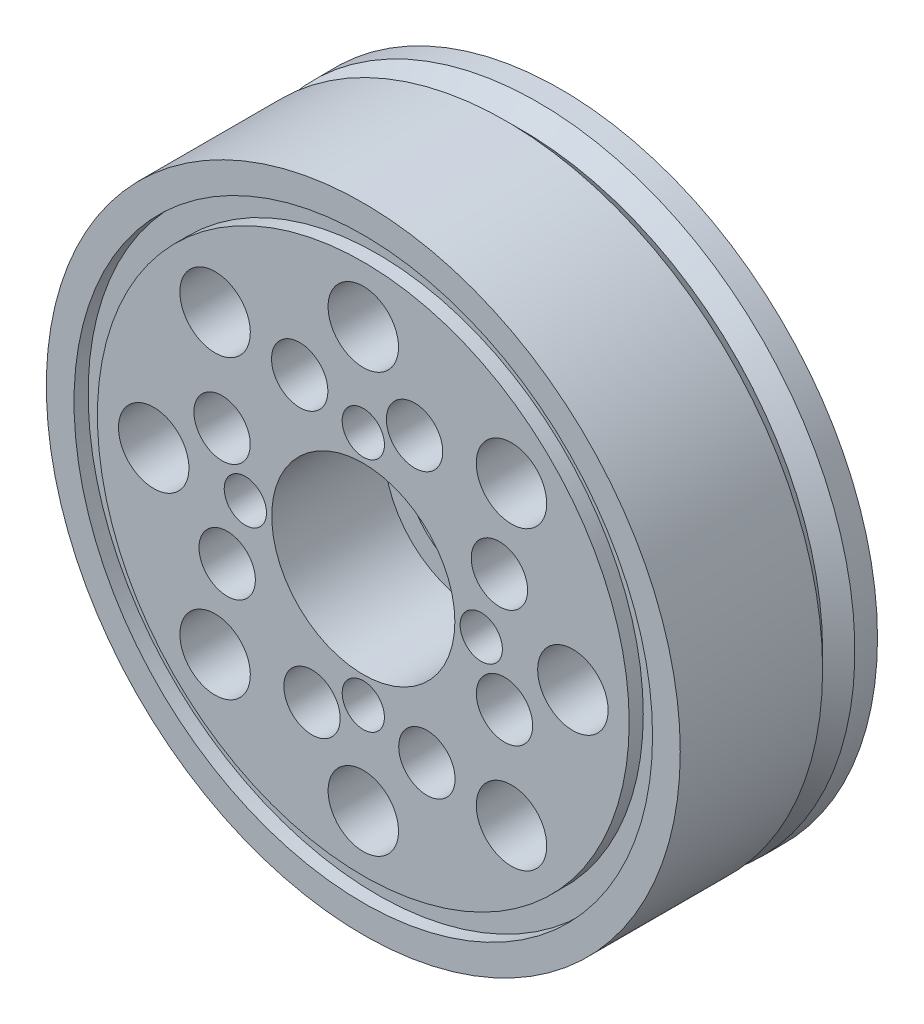
from build123d import *

# Parameters (mm, degrees)
SKETCH_1_R               = 22.5
EXTRUDE_1_DEPTH          = 14
SKETCH_4_R               = 20.533551365
SKETCH_4_R_2             = 18.873819988
CUT_EXTRUDE_2_DEPTH      = 1
SKETCH_5_R               = 6.5
CUT_EXTRUDE_3_DEPTH      = 8
SKETCH_6_R               = 5
CUT_EXTRUDE_4_DEPTH      = 8
SKETCH_7_R               = 1.5
CUT_EXTRUDE_5_DEPTH      = 5
PATTERN_CIRCULAR_1_COUNT = 4
SKETCH_8_R               = 2.5
CUT_EXTRUDE_6_DEPTH      = 5
PATTERN_CIRCULAR_2_COUNT = 8
SKETCH_9_R               = 2
CUT_EXTRUDE_10_DEPTH     = 5
PATTERN_CIRCULAR_3_COUNT = 8
SCALE_1_SCALE            = 1.2444444


with BuildPart() as part:
    # 草图1 → 凸台-拉伸1 (new body)
    with BuildSketch(Plane.XY):
        Circle(SKETCH_1_R)
    extrude(amount=EXTRUDE_1_DEPTH)

    # 草图4 → 切除-拉伸2 (cut)
    with BuildSketch(Plane.XY.offset(14)):
        Circle(SKETCH_4_R)
        Circle(SKETCH_4_R_2, mode=Mode.SUBTRACT)
    extrude(amount=-CUT_EXTRUDE_2_DEPTH, mode=Mode.SUBTRACT)

    # 草图5 → 切除-拉伸3 (cut)
    with BuildSketch(Plane.XY.offset(14)):
        Circle(SKETCH_5_R)
    extrude(amount=-CUT_EXTRUDE_3_DEPTH, mode=Mode.SUBTRACT)

    # 草图6 → 切除-拉伸4 (cut)
    with BuildSketch(Plane.XY.offset(6)):
        Circle(SKETCH_6_R)
    extrude(amount=-CUT_EXTRUDE_4_DEPTH, mode=Mode.SUBTRACT)

    # 草图7 → 切除-拉伸5 (cut)
    with BuildSketch(Plane.XY.offset(14)):
        with Locations((0, 8.372803667)):
            Circle(SKETCH_7_R)
    cut_extrude_5 = extrude(amount=-CUT_EXTRUDE_5_DEPTH, mode=Mode.SUBTRACT)

    # 阵列(圆周)1: 切除-拉伸5 ×4 about axis
    pattern_circular_1_axis = Axis((0, 0, 0), (0, 0, 1))
    for i in range(1, PATTERN_CIRCULAR_1_COUNT):
        add(cut_extrude_5.rotate(pattern_circular_1_axis, i * 360 / PATTERN_CIRCULAR_1_COUNT), mode=Mode.SUBTRACT)

    # 草图8 → 切除-拉伸6 (cut)
    with BuildSketch(Plane.XY.offset(14)):
        with Locations((0, 14.876496216)):
            Circle(SKETCH_8_R)
    cut_extrude_6 = extrude(amount=-CUT_EXTRUDE_6_DEPTH, mode=Mode.SUBTRACT)

    # 阵列(圆周)2: 切除-拉伸6 ×8 about axis
    pattern_circular_2_axis = Axis((0, 0, 0), (0, 0, 1))
    for i in range(1, PATTERN_CIRCULAR_2_COUNT):
        add(cut_extrude_6.rotate(pattern_circular_2_axis, i * 360 / PATTERN_CIRCULAR_2_COUNT), mode=Mode.SUBTRACT)

    # 草图9 → 切除-拉伸10 (cut)
    with BuildSketch(Plane.XY.offset(14)):
        with Locations((-4.513696744, 9.661753254)):
            Circle(SKETCH_9_R)
    cut_extrude_10 = extrude(amount=-CUT_EXTRUDE_10_DEPTH, mode=Mode.SUBTRACT)

    # 阵列(圆周)3: 切除-拉伸10 ×8 about axis
    pattern_circular_3_axis = Axis((0, 0, 0), (0, 0, 1))
    for i in range(1, PATTERN_CIRCULAR_3_COUNT):
        add(cut_extrude_10.rotate(pattern_circular_3_axis, i * 360 / PATTERN_CIRCULAR_3_COUNT), mode=Mode.SUBTRACT)


with BuildPart() as part_1:
    # 缩放比例1: scaled about (0, 0, 6.525153491)
    add(part.part.scale(SCALE_1_SCALE).moved(Location((0, 0, -1.59503723))))

    # 草图10 → 切除-旋转1 (revolve, cut)
    with BuildSketch(Plane(origin=(0, 0, 0), x_dir=(0, 0, -1), z_dir=(1, 0, 0))):
        Polygon((-0.40004552, 28.00491625), (-1.828401218, 26.576560552), (-3.256756916, 28.00491625), align=None)
    revolve(axis=Axis((0, 0, 0), (0, 0, 1)), mode=Mode.SUBTRACT)


solid = part_1.part
